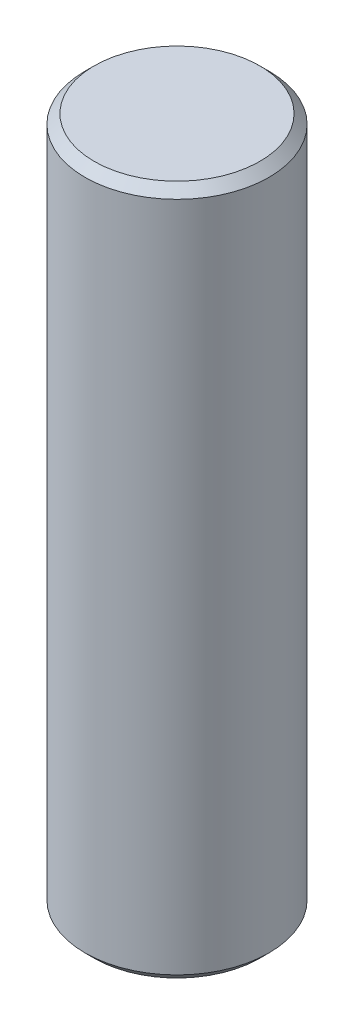
from build123d import *

# Parameters (mm, degrees)
SKETCH_1_R      = 2
EXTRUDE_1_DEPTH = 15
CHAMFER_1_SIZE  = 0.2


with BuildPart() as part:
    # 草图1 → 凸台-拉伸1 (new body)
    with BuildSketch(Plane(origin=(0, 0, 0), x_dir=(1, 0, 0), z_dir=(0, 1, 0))):
        Circle(SKETCH_1_R)
    extrude(amount=EXTRUDE_1_DEPTH)

    # 倒角1
    chamfer_1_edges = [part.edges().sort_by_distance(p)[0] for p in [
        (-2, 0, 0),
        (-2, 15, 0),
    ]]
    chamfer(chamfer_1_edges, length=CHAMFER_1_SIZE)


solid = part.part
